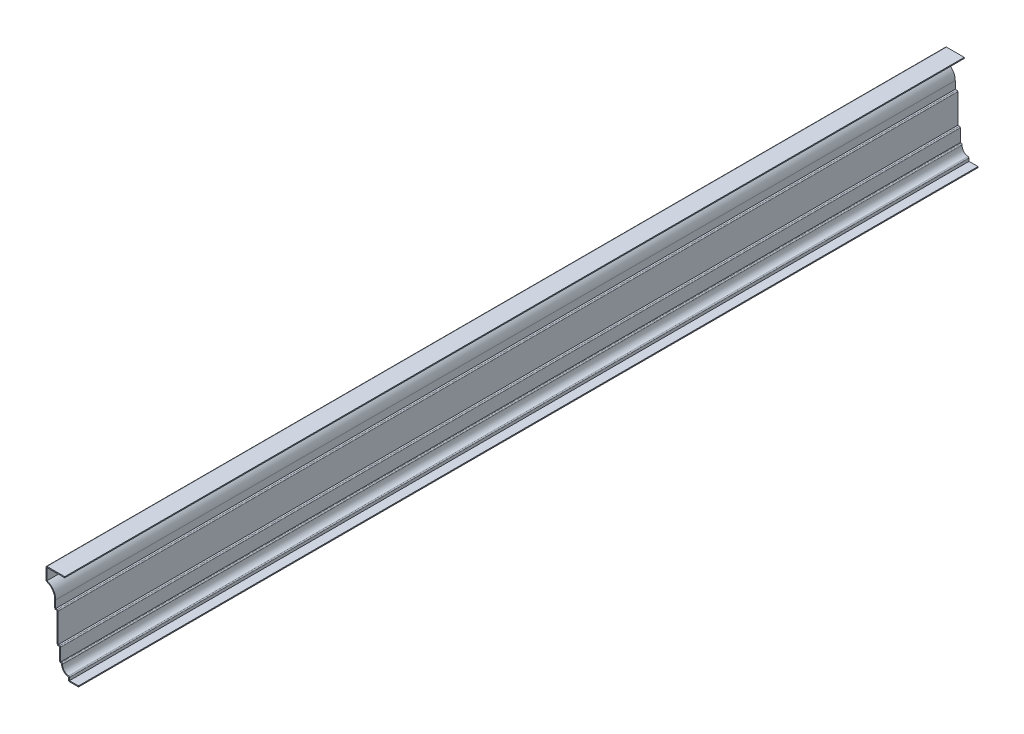
from build123d import *

# Parameters (mm, degrees)
EXTRUDE_THIN1_DEPTH = 1143
FILLET1_R           = 1.27


with BuildPart() as part:
    # Sketch1 → Extrude-Thin1 (new body)
    with BuildSketch(Plane.XY):
        with BuildLine():
            Line((0, 0), (-12.7, 0))
            Line((-12.7, 0), (-12.7, 4.7625))
            ThreePointArc((-12.7, 4.7625), (-19.213209814, 8.104687849), (-21.43125, 15.08125))
            Line((-21.43125, 15.08125), (-23.8125, 15.08125))
            Line((-23.8125, 15.08125), (-23.8125, 32.54375))
            Line((-23.8125, 32.54375), (-26.9875, 32.54375))
            Line((-26.9875, 32.54375), (-26.9875, 70.64375))
            Line((-26.9875, 70.64375), (-30.1625, 70.64375))
            Line((-30.1625, 70.64375), (-30.1625, 81.494072169))
            ThreePointArc((-30.1625, 81.494072169), (-33.258387834, 90.648043728), (-41.275, 96.04375))
            Line((-41.275, 96.04375), (-41.275, 112.7125))
            Line((-41.275, 112.7125), (-17.4625, 112.7125))
            Line((-17.4625, 112.7125), (-17.4625, 111.4425))
            Line((-17.4625, 111.4425), (-40.005, 111.4425))
            Line((-40.005, 111.4425), (-40.005, 96.983387034))
            ThreePointArc((-40.005, 96.983387034), (-31.95797777, 91.025684457), (-28.8925, 81.494072169))
            Line((-28.8925, 81.494072169), (-28.8925, 71.91375))
            Line((-28.8925, 71.91375), (-25.7175, 71.91375))
            Line((-25.7175, 71.91375), (-25.7175, 33.81375))
            Line((-25.7175, 33.81375), (-22.5425, 33.81375))
            Line((-22.5425, 33.81375), (-22.5425, 16.35125))
            Line((-22.5425, 16.35125), (-19.926963078, 16.35125))
            ThreePointArc((-19.926963078, 16.35125), (-18.318060907, 9.014168003), (-11.43, 6.018178122))
            Line((-11.43, 6.018178122), (-11.43, 1.27))
            Line((-11.43, 1.27), (0, 1.27))
            Line((0, 1.27), (0, 0))
        make_face()
    extrude(amount=-EXTRUDE_THIN1_DEPTH)

    # Fillet1
    fillet1_edges = [part.edges().sort_by_distance(p)[0] for p in [
        (-25.7175, 71.91375, -571.5),
        (-22.5425, 33.81375, -571.5),
        (-19.926963078, 16.35125, -571.5),
        (-11.43, 6.018178122, -571.5),
        (-12.7, 0, -571.5),
        (-23.8125, 15.08125, -571.5),
        (-26.9875, 32.54375, -571.5),
        (-30.1625, 70.64375, -571.5),
        (-41.275, 96.04375, -571.5),
        (-41.275, 112.7125, -571.5),
    ]]
    fillet(fillet1_edges, radius=FILLET1_R)


solid = part.part
